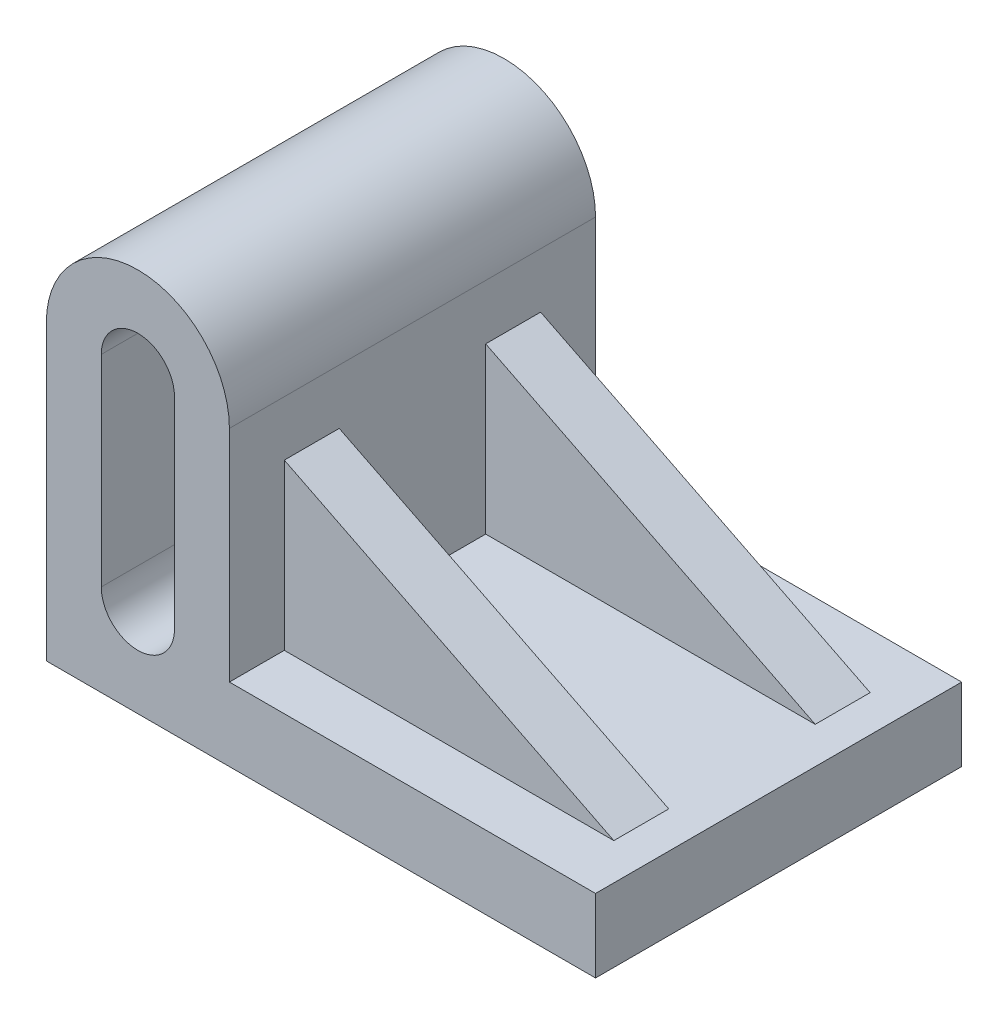
from build123d import *

# Parameters (mm, degrees)
SKETCH1_W           = 100
SKETCH1_H           = 20
BOSS_EXTRUDE1_DEPTH = 100
SKETCH2_W           = 90
SKETCH2_H           = 15
BOSS_EXTRUDE2_DEPTH = 45
CUT_EXTRUDE1_DEPTH  = 86


with BuildPart() as part:
    # Sketch1 → Boss-Extrude1 (new body)
    with BuildSketch(Plane.XY):
        with Locations((25, -30)):
            Rectangle(SKETCH1_W, SKETCH1_H)
        with BuildLine():
            ThreePointArc((-60, 17.087121525), (-70.916500663, 26.306936062), (-75, 40))
            Line((-75, 40), (-75, -40))
            Line((-75, -40), (-25, -40))
            Line((-25, -40), (-25, -20))
            Line((-25, -20), (-25, 40))
            ThreePointArc((-25, 40), (-29.083499337, 26.306936062), (-40, 17.087121525))
            Line((-40, 17.087121525), (-40, -15))
            ThreePointArc((-40, -15), (-50, -25), (-60, -15))
            Line((-60, -15), (-60, 17.087121525))
        make_face()
        with BuildLine():
            ThreePointArc((-40, 17.087121525), (-29.083499337, 26.306936062), (-25, 40))
            Line((-25, 40), (-40, 40))
            Line((-40, 40), (-40, 17.087121525))
        make_face()
        with BuildLine():
            ThreePointArc((-25, 40), (-50, 65), (-75, 40))
            Line((-75, 40), (-60, 40))
            ThreePointArc((-60, 40), (-50, 50), (-40, 40))
            Line((-40, 40), (-25, 40))
        make_face()
        with BuildLine():
            Line((-60, 40), (-75, 40))
            ThreePointArc((-75, 40), (-70.916500663, 26.306936062), (-60, 17.087121525))
            Line((-60, 17.087121525), (-60, 40))
        make_face()
    extrude(amount=BOSS_EXTRUDE1_DEPTH)

    # Sketch2 → Boss-Extrude2 (add)
    with BuildSketch(Plane(origin=(0, -20, 0), x_dir=(1, 0, 0), z_dir=(0, 1, 0))):
        with Locations((20, -77.5)):
            Rectangle(SKETCH2_W, SKETCH2_H)
        with Locations((20, -22.5)):
            Rectangle(SKETCH2_W, SKETCH2_H)
    extrude(amount=BOSS_EXTRUDE2_DEPTH)

    # Sketch3 → Cut-Extrude1 (cut, through all)
    with BuildSketch(Plane.XY.offset(85)):
        Polygon((-25, 25), (65, -20), (65, 25), align=None)
    extrude(amount=-CUT_EXTRUDE1_DEPTH, mode=Mode.SUBTRACT)


solid = part.part
